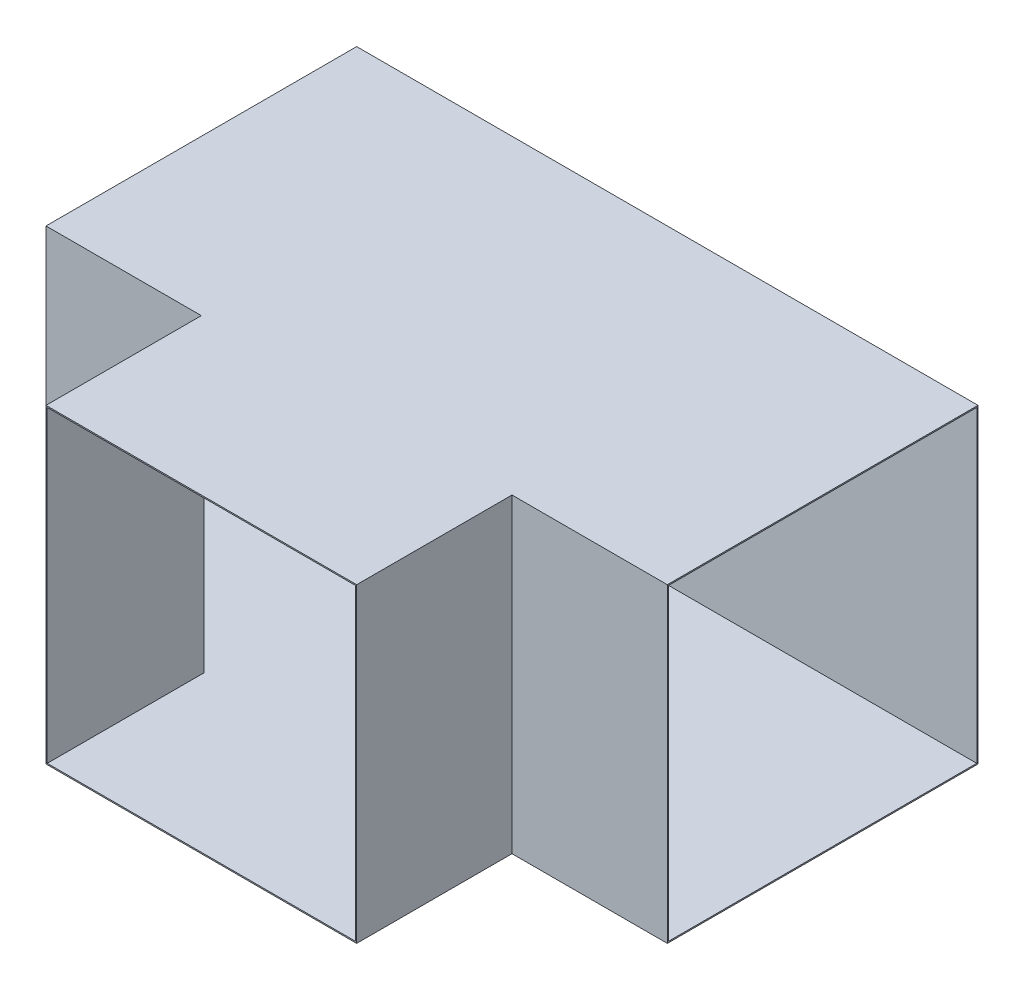
from build123d import *

# Parameters (mm, degrees)
SKETCH1_W           = 500
SKETCH1_H           = 500
SKETCH1_W_2         = 496
SKETCH1_H_2         = 496
EXTRUDE_THIN1_DEPTH = 500
SKETCH2_W           = 500
SKETCH2_H           = 500
SKETCH2_W_2         = 496
SKETCH2_H_2         = 496
EXTRUDE_THIN2_DEPTH = 250
CUT_EXTRUDE1_REACH  = 1348.291
SKETCH3_W           = 496
SKETCH3_H           = 496


with BuildPart() as part:
    # Sketch1 → Extrude-Thin1 (new, symmetric)
    with BuildSketch(Plane(origin=(0, 0, 0), x_dir=(0, 0, -1), z_dir=(1, 0, 0))):
        Rectangle(SKETCH1_W, SKETCH1_H)
        Rectangle(SKETCH1_W_2, SKETCH1_H_2, mode=Mode.SUBTRACT)
    extrude(amount=EXTRUDE_THIN1_DEPTH, both=True)

    # Sketch2 → Extrude-Thin2 (add)
    with BuildSketch(Plane(origin=(0, -250, 250), x_dir=(1, 0, 0), z_dir=(0, 0, -1))):
        with Locations((0, -250)):
            Rectangle(SKETCH2_W, SKETCH2_H)
        with Locations((0, -250)):
            Rectangle(SKETCH2_W_2, SKETCH2_H_2, mode=Mode.SUBTRACT)
    extrude(amount=-EXTRUDE_THIN2_DEPTH)

    # Sketch3 → Cut-Extrude1 (cut, up to next)
    with BuildSketch(Plane(origin=(0, -750, 500), x_dir=(1, 0, 0), z_dir=(0, 0, -1)), mode=Mode.PRIVATE) as cut_extrude1_sk1:
        with Locations((0, -750)):
            Rectangle(SKETCH3_W, SKETCH3_H)
    cut_extrude1_tool1 = extrude(cut_extrude1_sk1.sketch, amount=CUT_EXTRUDE1_REACH, mode=Mode.PRIVATE) & part.part
    add(cut_extrude1_tool1.solids().sort_by_distance((0, 0, 500))[0], mode=Mode.SUBTRACT)


solid = part.part
